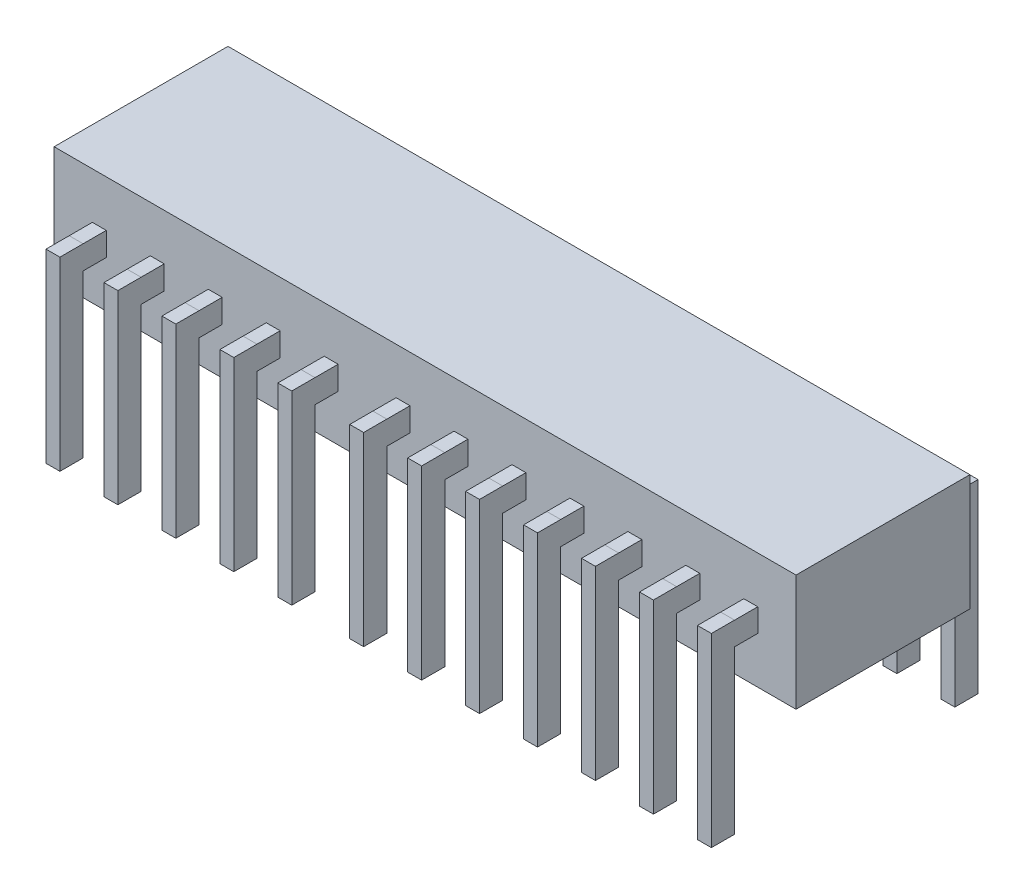
from build123d import *

# Parameters (mm, degrees)
BOSS_EXTRUDE3_DEPTH         = 2507.5
BOSS_EXTRUDE6_DEPTH         = 508
BOSS_EXTRUDE6_DEPTH_BACK    = 7494
SKETCH1_14_W                = 600
SKETCH1_14_H                = 1000
BOSS_EXTRUDE6_2_DEPTH       = 508
BOSS_EXTRUDE6_2_DEPTH_BACK  = 7494
BOSS_EXTRUDE6_3_DEPTH       = 508
BOSS_EXTRUDE6_3_DEPTH_BACK  = 7494
BOSS_EXTRUDE6_4_DEPTH       = 508
BOSS_EXTRUDE6_4_DEPTH_BACK  = 7494
BOSS_EXTRUDE6_5_DEPTH       = 508
BOSS_EXTRUDE6_5_DEPTH_BACK  = 7494
BOSS_EXTRUDE6_6_DEPTH       = 508
BOSS_EXTRUDE6_6_DEPTH_BACK  = 7494
BOSS_EXTRUDE6_7_DEPTH       = 508
BOSS_EXTRUDE6_7_DEPTH_BACK  = 7494
BOSS_EXTRUDE6_8_DEPTH       = 508
BOSS_EXTRUDE6_8_DEPTH_BACK  = 7494
BOSS_EXTRUDE6_9_DEPTH       = 508
BOSS_EXTRUDE6_9_DEPTH_BACK  = 7494
BOSS_EXTRUDE6_10_DEPTH      = 508
BOSS_EXTRUDE6_10_DEPTH_BACK = 7494
BOSS_EXTRUDE6_11_DEPTH      = 508
BOSS_EXTRUDE6_11_DEPTH_BACK = 7494
BOSS_EXTRUDE6_12_DEPTH      = 508
BOSS_EXTRUDE6_12_DEPTH_BACK = 7494
BOSS_EXTRUDE6_13_DEPTH      = 508
BOSS_EXTRUDE6_13_DEPTH_BACK = 7494
BOSS_EXTRUDE6_14_DEPTH      = 508
BOSS_EXTRUDE6_14_DEPTH_BACK = 7494
BOSS_EXTRUDE6_15_DEPTH      = 508
BOSS_EXTRUDE6_15_DEPTH_BACK = 7494
BOSS_EXTRUDE6_16_DEPTH      = 508
BOSS_EXTRUDE6_16_DEPTH_BACK = 7494
BOSS_EXTRUDE6_17_DEPTH      = 508
BOSS_EXTRUDE6_17_DEPTH_BACK = 7494
BOSS_EXTRUDE6_18_DEPTH      = 508
BOSS_EXTRUDE6_18_DEPTH_BACK = 7494
BOSS_EXTRUDE6_19_DEPTH      = 508
BOSS_EXTRUDE6_19_DEPTH_BACK = 7494
BOSS_EXTRUDE6_20_DEPTH      = 508
BOSS_EXTRUDE6_20_DEPTH_BACK = 7494
SKETCH1_17_W                = 600
SKETCH1_17_H                = 1000
BOSS_EXTRUDE8_DEPTH         = 507.5
BOSS_EXTRUDE9_DEPTH         = 500
BOSS_EXTRUDE9_DEPTH_BACK    = 7501
SKETCH1_18_W                = 600
SKETCH1_18_H                = 1000
BOSS_EXTRUDE9_2_DEPTH       = 500
BOSS_EXTRUDE9_2_DEPTH_BACK  = 7501
BOSS_EXTRUDE9_3_DEPTH       = 500
BOSS_EXTRUDE9_3_DEPTH_BACK  = 7501
BOSS_EXTRUDE9_4_DEPTH       = 500
BOSS_EXTRUDE9_4_DEPTH_BACK  = 7501
SKETCH1_19_W                = 600
SKETCH1_19_H                = 1000
BOSS_EXTRUDE10_DEPTH        = 498


with BuildPart() as part:
    # Sketch1 → Boss-Extrude3 (new, symmetric)
    with BuildSketch(Plane(origin=(0, 0, 0), x_dir=(1, 0, 0), z_dir=(0, 1, 0))):
        Polygon((-13500, 3750), (-13500, -3750), (-11850, -3750), (-11250, -3750), (-9350, -3750), (-8750, -3750), (-6850, -3750), (-6250, -3750), (-4350, -3750), (-3750, -3750), (-1850, -3750), (-1250, -3750), (1250, -3750), (1850, -3750), (3750, -3750), (4350, -3750), (6250, -3750), (6850, -3750), (8750, -3750), (9350, -3750), (11250, -3750), (11850, -3750), (13750, -3750), (14350, -3750), (16250, -3750), (16850, -3750), (18500, -3750), (18500.002534716, -3750), (18500.002534716, 3750), (16850, 3750), (16250, 3750), (14350, 3750), (13750, 3750), (11850, 3750), (11250, 3750), (9350, 3750), (8750, 3750), (6850, 3750), (6250, 3750), (4350, 3750), (3750, 3750), (1850, 3750), (1250, 3750), (-1250, 3750), (-1850, 3750), (-3750, 3750), (-4350, 3750), (-6250, 3750), (-6850, 3750), (-8750, 3750), (-9350, 3750), (-11250, 3750), (-11850, 3750), align=None)
    extrude(amount=BOSS_EXTRUDE3_DEPTH, both=True)



with BuildPart() as body_2:
    # Sketch1_14 → Boss-Extrude6 (new, two sides: drawn at the far end of the back side and taken through both)
    with BuildSketch(Plane(origin=(0, 0, 0), x_dir=(1, 0, 0), z_dir=(0, 1, 0)).offset(-BOSS_EXTRUDE6_DEPTH_BACK)):
        with Locations((-11550, -5250)):
            Rectangle(SKETCH1_14_W, SKETCH1_14_H)
    extrude(amount=BOSS_EXTRUDE6_DEPTH + BOSS_EXTRUDE6_DEPTH_BACK)


with BuildPart() as body_3:
    # Sketch1_14 → Boss-Extrude6 2 (new, two sides: drawn at the far end of the back side and taken through both)
    with BuildSketch(Plane(origin=(0, 0, 0), x_dir=(1, 0, 0), z_dir=(0, 1, 0)).offset(-BOSS_EXTRUDE6_2_DEPTH_BACK)):
        with Locations((-11550, 5250)):
            Rectangle(SKETCH1_14_W, SKETCH1_14_H)
    extrude(amount=BOSS_EXTRUDE6_2_DEPTH + BOSS_EXTRUDE6_2_DEPTH_BACK)


with BuildPart() as body_4:
    # Sketch1_14 → Boss-Extrude6 3 (new, two sides: drawn at the far end of the back side and taken through both)
    with BuildSketch(Plane(origin=(0, 0, 0), x_dir=(1, 0, 0), z_dir=(0, 1, 0)).offset(-BOSS_EXTRUDE6_3_DEPTH_BACK)):
        with Locations((-9050, -5250)):
            Rectangle(SKETCH1_14_W, SKETCH1_14_H)
    extrude(amount=BOSS_EXTRUDE6_3_DEPTH + BOSS_EXTRUDE6_3_DEPTH_BACK)


with BuildPart() as body_5:
    # Sketch1_14 → Boss-Extrude6 4 (new, two sides: drawn at the far end of the back side and taken through both)
    with BuildSketch(Plane(origin=(0, 0, 0), x_dir=(1, 0, 0), z_dir=(0, 1, 0)).offset(-BOSS_EXTRUDE6_4_DEPTH_BACK)):
        with Locations((-9050, 5250)):
            Rectangle(SKETCH1_14_W, SKETCH1_14_H)
    extrude(amount=BOSS_EXTRUDE6_4_DEPTH + BOSS_EXTRUDE6_4_DEPTH_BACK)


with BuildPart() as body_6:
    # Sketch1_14 → Boss-Extrude6 5 (new, two sides: drawn at the far end of the back side and taken through both)
    with BuildSketch(Plane(origin=(0, 0, 0), x_dir=(1, 0, 0), z_dir=(0, 1, 0)).offset(-BOSS_EXTRUDE6_5_DEPTH_BACK)):
        with Locations((-6550, -5250)):
            Rectangle(SKETCH1_14_W, SKETCH1_14_H)
    extrude(amount=BOSS_EXTRUDE6_5_DEPTH + BOSS_EXTRUDE6_5_DEPTH_BACK)


with BuildPart() as body_7:
    # Sketch1_14 → Boss-Extrude6 6 (new, two sides: drawn at the far end of the back side and taken through both)
    with BuildSketch(Plane(origin=(0, 0, 0), x_dir=(1, 0, 0), z_dir=(0, 1, 0)).offset(-BOSS_EXTRUDE6_6_DEPTH_BACK)):
        with Locations((-6550, 5250)):
            Rectangle(SKETCH1_14_W, SKETCH1_14_H)
    extrude(amount=BOSS_EXTRUDE6_6_DEPTH + BOSS_EXTRUDE6_6_DEPTH_BACK)


with BuildPart() as body_8:
    # Sketch1_14 → Boss-Extrude6 7 (new, two sides: drawn at the far end of the back side and taken through both)
    with BuildSketch(Plane(origin=(0, 0, 0), x_dir=(1, 0, 0), z_dir=(0, 1, 0)).offset(-BOSS_EXTRUDE6_7_DEPTH_BACK)):
        with Locations((-4050, -5250)):
            Rectangle(SKETCH1_14_W, SKETCH1_14_H)
    extrude(amount=BOSS_EXTRUDE6_7_DEPTH + BOSS_EXTRUDE6_7_DEPTH_BACK)


with BuildPart() as body_9:
    # Sketch1_14 → Boss-Extrude6 8 (new, two sides: drawn at the far end of the back side and taken through both)
    with BuildSketch(Plane(origin=(0, 0, 0), x_dir=(1, 0, 0), z_dir=(0, 1, 0)).offset(-BOSS_EXTRUDE6_8_DEPTH_BACK)):
        with Locations((-4050, 5250)):
            Rectangle(SKETCH1_14_W, SKETCH1_14_H)
    extrude(amount=BOSS_EXTRUDE6_8_DEPTH + BOSS_EXTRUDE6_8_DEPTH_BACK)


with BuildPart() as body_10:
    # Sketch1_14 → Boss-Extrude6 9 (new, two sides: drawn at the far end of the back side and taken through both)
    with BuildSketch(Plane(origin=(0, 0, 0), x_dir=(1, 0, 0), z_dir=(0, 1, 0)).offset(-BOSS_EXTRUDE6_9_DEPTH_BACK)):
        with Locations((-1550, -5250)):
            Rectangle(SKETCH1_14_W, SKETCH1_14_H)
    extrude(amount=BOSS_EXTRUDE6_9_DEPTH + BOSS_EXTRUDE6_9_DEPTH_BACK)


with BuildPart() as body_11:
    # Sketch1_14 → Boss-Extrude6 10 (new, two sides: drawn at the far end of the back side and taken through both)
    with BuildSketch(Plane(origin=(0, 0, 0), x_dir=(1, 0, 0), z_dir=(0, 1, 0)).offset(-BOSS_EXTRUDE6_10_DEPTH_BACK)):
        with Locations((-1550, 5250)):
            Rectangle(SKETCH1_14_W, SKETCH1_14_H)
    extrude(amount=BOSS_EXTRUDE6_10_DEPTH + BOSS_EXTRUDE6_10_DEPTH_BACK)


with BuildPart() as body_12:
    # Sketch1_14 → Boss-Extrude6 11 (new, two sides: drawn at the far end of the back side and taken through both)
    with BuildSketch(Plane(origin=(0, 0, 0), x_dir=(1, 0, 0), z_dir=(0, 1, 0)).offset(-BOSS_EXTRUDE6_11_DEPTH_BACK)):
        with Locations((1550, -5250)):
            Rectangle(SKETCH1_14_W, SKETCH1_14_H)
    extrude(amount=BOSS_EXTRUDE6_11_DEPTH + BOSS_EXTRUDE6_11_DEPTH_BACK)


with BuildPart() as body_13:
    # Sketch1_14 → Boss-Extrude6 12 (new, two sides: drawn at the far end of the back side and taken through both)
    with BuildSketch(Plane(origin=(0, 0, 0), x_dir=(1, 0, 0), z_dir=(0, 1, 0)).offset(-BOSS_EXTRUDE6_12_DEPTH_BACK)):
        with Locations((1550, 5250)):
            Rectangle(SKETCH1_14_W, SKETCH1_14_H)
    extrude(amount=BOSS_EXTRUDE6_12_DEPTH + BOSS_EXTRUDE6_12_DEPTH_BACK)


with BuildPart() as body_14:
    # Sketch1_14 → Boss-Extrude6 13 (new, two sides: drawn at the far end of the back side and taken through both)
    with BuildSketch(Plane(origin=(0, 0, 0), x_dir=(1, 0, 0), z_dir=(0, 1, 0)).offset(-BOSS_EXTRUDE6_13_DEPTH_BACK)):
        with Locations((4050, -5250)):
            Rectangle(SKETCH1_14_W, SKETCH1_14_H)
    extrude(amount=BOSS_EXTRUDE6_13_DEPTH + BOSS_EXTRUDE6_13_DEPTH_BACK)


with BuildPart() as body_15:
    # Sketch1_14 → Boss-Extrude6 14 (new, two sides: drawn at the far end of the back side and taken through both)
    with BuildSketch(Plane(origin=(0, 0, 0), x_dir=(1, 0, 0), z_dir=(0, 1, 0)).offset(-BOSS_EXTRUDE6_14_DEPTH_BACK)):
        with Locations((4050, 5250)):
            Rectangle(SKETCH1_14_W, SKETCH1_14_H)
    extrude(amount=BOSS_EXTRUDE6_14_DEPTH + BOSS_EXTRUDE6_14_DEPTH_BACK)


with BuildPart() as body_16:
    # Sketch1_14 → Boss-Extrude6 15 (new, two sides: drawn at the far end of the back side and taken through both)
    with BuildSketch(Plane(origin=(0, 0, 0), x_dir=(1, 0, 0), z_dir=(0, 1, 0)).offset(-BOSS_EXTRUDE6_15_DEPTH_BACK)):
        with Locations((6550, -5250)):
            Rectangle(SKETCH1_14_W, SKETCH1_14_H)
    extrude(amount=BOSS_EXTRUDE6_15_DEPTH + BOSS_EXTRUDE6_15_DEPTH_BACK)


with BuildPart() as body_17:
    # Sketch1_14 → Boss-Extrude6 16 (new, two sides: drawn at the far end of the back side and taken through both)
    with BuildSketch(Plane(origin=(0, 0, 0), x_dir=(1, 0, 0), z_dir=(0, 1, 0)).offset(-BOSS_EXTRUDE6_16_DEPTH_BACK)):
        with Locations((6550, 5250)):
            Rectangle(SKETCH1_14_W, SKETCH1_14_H)
    extrude(amount=BOSS_EXTRUDE6_16_DEPTH + BOSS_EXTRUDE6_16_DEPTH_BACK)


with BuildPart() as body_18:
    # Sketch1_14 → Boss-Extrude6 17 (new, two sides: drawn at the far end of the back side and taken through both)
    with BuildSketch(Plane(origin=(0, 0, 0), x_dir=(1, 0, 0), z_dir=(0, 1, 0)).offset(-BOSS_EXTRUDE6_17_DEPTH_BACK)):
        with Locations((9050, -5250)):
            Rectangle(SKETCH1_14_W, SKETCH1_14_H)
    extrude(amount=BOSS_EXTRUDE6_17_DEPTH + BOSS_EXTRUDE6_17_DEPTH_BACK)


with BuildPart() as body_19:
    # Sketch1_14 → Boss-Extrude6 18 (new, two sides: drawn at the far end of the back side and taken through both)
    with BuildSketch(Plane(origin=(0, 0, 0), x_dir=(1, 0, 0), z_dir=(0, 1, 0)).offset(-BOSS_EXTRUDE6_18_DEPTH_BACK)):
        with Locations((9050, 5250)):
            Rectangle(SKETCH1_14_W, SKETCH1_14_H)
    extrude(amount=BOSS_EXTRUDE6_18_DEPTH + BOSS_EXTRUDE6_18_DEPTH_BACK)


with BuildPart() as body_20:
    # Sketch1_14 → Boss-Extrude6 19 (new, two sides: drawn at the far end of the back side and taken through both)
    with BuildSketch(Plane(origin=(0, 0, 0), x_dir=(1, 0, 0), z_dir=(0, 1, 0)).offset(-BOSS_EXTRUDE6_19_DEPTH_BACK)):
        with Locations((11550, -5250)):
            Rectangle(SKETCH1_14_W, SKETCH1_14_H)
    extrude(amount=BOSS_EXTRUDE6_19_DEPTH + BOSS_EXTRUDE6_19_DEPTH_BACK)


with BuildPart() as body_21:
    # Sketch1_14 → Boss-Extrude6 20 (new, two sides: drawn at the far end of the back side and taken through both)
    with BuildSketch(Plane(origin=(0, 0, 0), x_dir=(1, 0, 0), z_dir=(0, 1, 0)).offset(-BOSS_EXTRUDE6_20_DEPTH_BACK)):
        with Locations((11550, 5250)):
            Rectangle(SKETCH1_14_W, SKETCH1_14_H)
    extrude(amount=BOSS_EXTRUDE6_20_DEPTH + BOSS_EXTRUDE6_20_DEPTH_BACK)


with BuildPart() as part_1:
    add(part.part)

    add(body_2.part)  # Boss-Extrude8 merges body 2

    add(body_3.part)  # Boss-Extrude8 merges body 3

    add(body_4.part)  # Boss-Extrude8 merges body 4

    add(body_5.part)  # Boss-Extrude8 merges body 5

    add(body_6.part)  # Boss-Extrude8 merges body 6

    add(body_7.part)  # Boss-Extrude8 merges body 7

    add(body_8.part)  # Boss-Extrude8 merges body 8

    add(body_9.part)  # Boss-Extrude8 merges body 9

    add(body_10.part)  # Boss-Extrude8 merges body 10

    add(body_11.part)  # Boss-Extrude8 merges body 11

    add(body_12.part)  # Boss-Extrude8 merges body 12

    add(body_13.part)  # Boss-Extrude8 merges body 13

    add(body_14.part)  # Boss-Extrude8 merges body 14

    add(body_15.part)  # Boss-Extrude8 merges body 15

    add(body_16.part)  # Boss-Extrude8 merges body 16

    add(body_17.part)  # Boss-Extrude8 merges body 17

    add(body_18.part)  # Boss-Extrude8 merges body 18

    add(body_19.part)  # Boss-Extrude8 merges body 19

    add(body_20.part)  # Boss-Extrude8 merges body 20

    add(body_21.part)  # Boss-Extrude8 merges body 21
    # Sketch1_17 → Boss-Extrude8 (add, symmetric)
    with BuildSketch(Plane(origin=(0, 0, 0), x_dir=(1, 0, 0), z_dir=(0, 1, 0))):
        with Locations((-11550, -4250)):
            Rectangle(SKETCH1_17_W, SKETCH1_17_H)
        with Locations((-11550, 4250)):
            Rectangle(SKETCH1_17_W, SKETCH1_17_H)
        with Locations((-9050, -4250)):
            Rectangle(SKETCH1_17_W, SKETCH1_17_H)
        with Locations((-9050, 4250)):
            Rectangle(SKETCH1_17_W, SKETCH1_17_H)
        with Locations((-6550, -4250)):
            Rectangle(SKETCH1_17_W, SKETCH1_17_H)
        with Locations((-6550, 4250)):
            Rectangle(SKETCH1_17_W, SKETCH1_17_H)
        with Locations((-4050, -4250)):
            Rectangle(SKETCH1_17_W, SKETCH1_17_H)
        with Locations((-4050, 4250)):
            Rectangle(SKETCH1_17_W, SKETCH1_17_H)
        with Locations((-1550, -4250)):
            Rectangle(SKETCH1_17_W, SKETCH1_17_H)
        with Locations((-1550, 4250)):
            Rectangle(SKETCH1_17_W, SKETCH1_17_H)
        with Locations((1550, -4250)):
            Rectangle(SKETCH1_17_W, SKETCH1_17_H)
        with Locations((1550, 4250)):
            Rectangle(SKETCH1_17_W, SKETCH1_17_H)
        with Locations((4050, -4250)):
            Rectangle(SKETCH1_17_W, SKETCH1_17_H)
        with Locations((4050, 4250)):
            Rectangle(SKETCH1_17_W, SKETCH1_17_H)
        with Locations((6550, -4250)):
            Rectangle(SKETCH1_17_W, SKETCH1_17_H)
        with Locations((6550, 4250)):
            Rectangle(SKETCH1_17_W, SKETCH1_17_H)
        with Locations((9050, -4250)):
            Rectangle(SKETCH1_17_W, SKETCH1_17_H)
        with Locations((9050, 4250)):
            Rectangle(SKETCH1_17_W, SKETCH1_17_H)
        with Locations((11550, -4250)):
            Rectangle(SKETCH1_17_W, SKETCH1_17_H)
        with Locations((11550, 4250)):
            Rectangle(SKETCH1_17_W, SKETCH1_17_H)
    extrude(amount=BOSS_EXTRUDE8_DEPTH, both=True)



with BuildPart() as body_2_2:
    # Sketch1_18 → Boss-Extrude9 (new, two sides: drawn at the far end of the back side and taken through both)
    with BuildSketch(Plane(origin=(0, 0, 0), x_dir=(1, 0, 0), z_dir=(0, 1, 0)).offset(-BOSS_EXTRUDE9_DEPTH_BACK)):
        with Locations((14050, -5250)):
            Rectangle(SKETCH1_18_W, SKETCH1_18_H)
    extrude(amount=BOSS_EXTRUDE9_DEPTH + BOSS_EXTRUDE9_DEPTH_BACK)


with BuildPart() as body_3_2:
    # Sketch1_18 → Boss-Extrude9 2 (new, two sides: drawn at the far end of the back side and taken through both)
    with BuildSketch(Plane(origin=(0, 0, 0), x_dir=(1, 0, 0), z_dir=(0, 1, 0)).offset(-BOSS_EXTRUDE9_2_DEPTH_BACK)):
        with Locations((14050, 5250)):
            Rectangle(SKETCH1_18_W, SKETCH1_18_H)
    extrude(amount=BOSS_EXTRUDE9_2_DEPTH + BOSS_EXTRUDE9_2_DEPTH_BACK)


with BuildPart() as body_4_2:
    # Sketch1_18 → Boss-Extrude9 3 (new, two sides: drawn at the far end of the back side and taken through both)
    with BuildSketch(Plane(origin=(0, 0, 0), x_dir=(1, 0, 0), z_dir=(0, 1, 0)).offset(-BOSS_EXTRUDE9_3_DEPTH_BACK)):
        with Locations((16550, -5250)):
            Rectangle(SKETCH1_18_W, SKETCH1_18_H)
    extrude(amount=BOSS_EXTRUDE9_3_DEPTH + BOSS_EXTRUDE9_3_DEPTH_BACK)


with BuildPart() as body_5_2:
    # Sketch1_18 → Boss-Extrude9 4 (new, two sides: drawn at the far end of the back side and taken through both)
    with BuildSketch(Plane(origin=(0, 0, 0), x_dir=(1, 0, 0), z_dir=(0, 1, 0)).offset(-BOSS_EXTRUDE9_4_DEPTH_BACK)):
        with Locations((16550, 5250)):
            Rectangle(SKETCH1_18_W, SKETCH1_18_H)
    extrude(amount=BOSS_EXTRUDE9_4_DEPTH + BOSS_EXTRUDE9_4_DEPTH_BACK)


with BuildPart() as part_2:
    add(part_1.part)

    add(body_2_2.part)  # Boss-Extrude10 merges body 2 2

    add(body_3_2.part)  # Boss-Extrude10 merges body 3 2

    add(body_4_2.part)  # Boss-Extrude10 merges body 4 2

    add(body_5_2.part)  # Boss-Extrude10 merges body 5 2
    # Sketch1_19 → Boss-Extrude10 (add, symmetric)
    with BuildSketch(Plane(origin=(0, 0, 0), x_dir=(1, 0, 0), z_dir=(0, 1, 0))):
        with Locations((14050, -4250)):
            Rectangle(SKETCH1_19_W, SKETCH1_19_H)
        with Locations((14050, 4250)):
            Rectangle(SKETCH1_19_W, SKETCH1_19_H)
        with Locations((16550, -4250)):
            Rectangle(SKETCH1_19_W, SKETCH1_19_H)
        with Locations((16550, 4250)):
            Rectangle(SKETCH1_19_W, SKETCH1_19_H)
    extrude(amount=BOSS_EXTRUDE10_DEPTH, both=True)


solid = part_2.part
